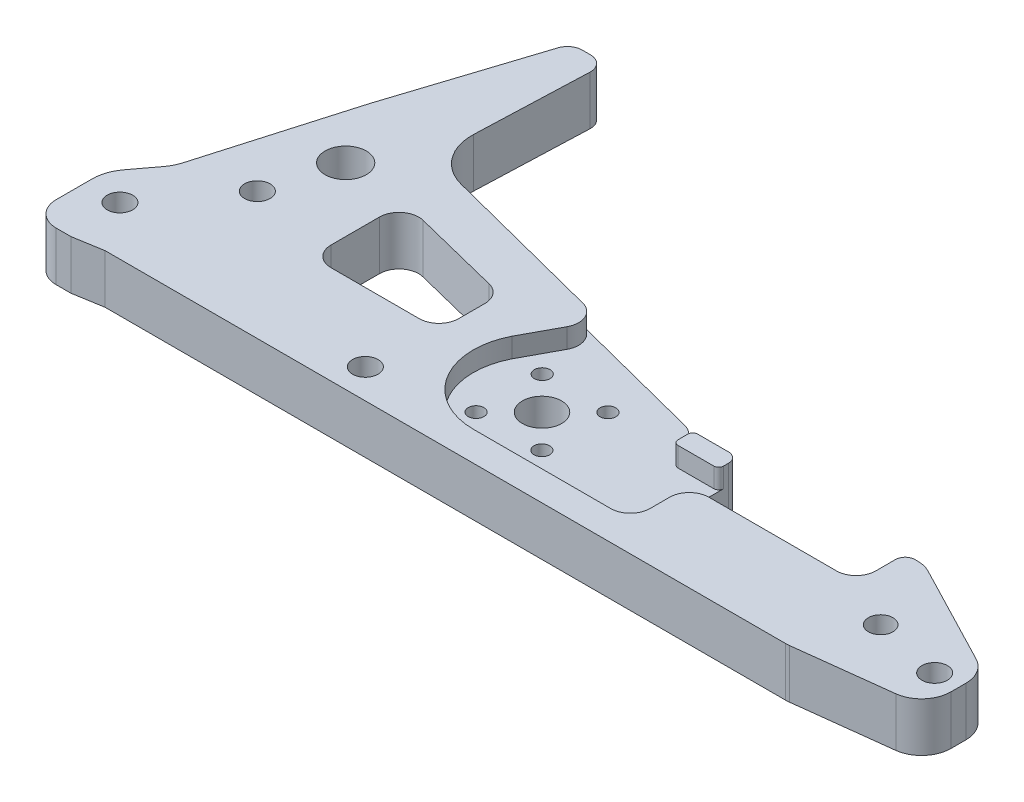
from build123d import *

# Parameters (mm, degrees)
SKETCH1_R           = 2.6
SKETCH1_R_2         = 4.2
SKETCH1_R_3         = 2.5
BOSS_EXTRUDE1_DEPTH = 10
FILLET2_R           = 6
FILLET3_R           = 3
CUT_EXTRUDE1_DEPTH  = 11
SKETCH7_R           = 2.6
CUT_EXTRUDE4_DEPTH  = 11
FILLET8_R           = 5
FILLET9_R           = 4
SKETCH10_W          = 34
SKETCH10_H          = 10
CUT_EXTRUDE6_DEPTH  = 11
FILLET11_R          = 2
CUT_EXTRUDE7_DEPTH  = 4
FILLET13_R          = 10
FILLET14_R          = 4
FILLET15_R          = 1
FILLET16_R          = 4
FILLET17_R          = 4
SKETCH13_R          = 4
CUT_EXTRUDE8_DEPTH  = 10
FILLET19_R          = 8
SKETCH14_R          = 1.6
CUT_EXTRUDE9_DEPTH  = 10


with BuildPart() as part:
    # Sketch1 → Boss-Extrude1 (new body)
    with BuildSketch(Plane(origin=(0, 0, 0), x_dir=(1, 0, 0), z_dir=(0, 1, 0))):
        Polygon((164, 15), (139, 28), (91.716233646, 28), (86.716233646, 32), (16.716233646, 50), (18, 84), (11, 84), (1, 53), (-8, 22), (-14, 14), (-14, 2), (-14, -1), (-6, -1), (0, 0), (139, 0), (164, 3), align=None)
        with Locations((-7, 10)):
            Circle(SKETCH1_R, mode=Mode.SUBTRACT)
        with Locations((159, 10)):
            Circle(SKETCH1_R, mode=Mode.SUBTRACT)
        with Locations((5, 26)):
            Circle(SKETCH1_R, mode=Mode.SUBTRACT)
        with Locations((9, 40)):
            Circle(SKETCH1_R_2, mode=Mode.SUBTRACT)
        with Locations((145, 13)):
            Circle(SKETCH1_R_3, mode=Mode.SUBTRACT)
    extrude(amount=BOSS_EXTRUDE1_DEPTH)

    # Fillet2
    fillet2_edges = [part.edges().sort_by_distance(p)[0] for p in [
        (139, 5, -28),
        (164, 5, -15),
        (164, 5, -3),
        (139, 5, 0),
    ]]
    fillet(fillet2_edges, radius=FILLET2_R)

    # Fillet3
    fillet3_edges = [part.edges().sort_by_distance(p)[0] for p in [
        (11, 5, -84),
        (18, 5, -84),
    ]]
    fillet(fillet3_edges, radius=FILLET3_R)

    # Sketch4 → Cut-Extrude1 (cut, through all)
    with BuildSketch(Plane(origin=(0, 10, 0), x_dir=(1, 0, 0), z_dir=(0, 1, 0))):
        Polygon((22, 39), (22, 20), (48, 20), (48, 32.5), align=None)
    extrude(amount=-CUT_EXTRUDE1_DEPTH, mode=Mode.SUBTRACT)

    # Sketch7 → Cut-Extrude4 (cut, through all)
    with BuildSketch(Plane(origin=(0, 10, 0), x_dir=(1, 0, 0), z_dir=(0, 1, 0))):
        with Locations((47, 6)):
            Circle(SKETCH7_R)
    extrude(amount=-CUT_EXTRUDE4_DEPTH, mode=Mode.SUBTRACT)

    # Fillet8
    fillet8_edges = [part.edges().sort_by_distance(p)[0] for p in [
        (-14, 5, 1),
    ]]
    fillet(fillet8_edges, radius=FILLET8_R)

    # Fillet9
    fillet9_edges = [part.edges().sort_by_distance(p)[0] for p in [
        (22, 5, -39),
        (48, 5, -32.5),
        (48, 5, -20),
        (22, 5, -20),
    ]]
    fillet(fillet9_edges, radius=FILLET9_R)

    # Sketch10 → Cut-Extrude6 (cut, through all)
    with BuildSketch(Plane(origin=(0, 10, 0), x_dir=(1, 0, 0), z_dir=(0, 1, 0))):
        with Locations((118, 23)):
            Rectangle(SKETCH10_W, SKETCH10_H)
    extrude(amount=-CUT_EXTRUDE6_DEPTH, mode=Mode.SUBTRACT)

    # Fillet11
    fillet11_edges = [part.edges().sort_by_distance(p)[0] for p in [
        (101, 5, -28),
        (135, 5, -28),
    ]]
    fillet(fillet11_edges, radius=FILLET11_R)

    # Sketch12 → Cut-Extrude7 (cut)
    with BuildSketch(Plane(origin=(0, 10, 0), x_dir=(1, 0, 0), z_dir=(0, 1, 0))):
        with BuildLine():
            Line((86.716233646, 32), (91.716233646, 28))
            Line((91.716233646, 28), (91.716233646, 24))
            Line((91.716233646, 24), (101, 24))
            Line((101, 24), (101, 6))
            Line((101, 6), (69, 6))
            ThreePointArc((69, 6), (57.064930536, 12.681932162), (56.522621715, 26.349411873))
            Line((56.522621715, 26.349411873), (62.882866971, 38.128580002))
            Line((62.882866971, 38.128580002), (86.716233646, 32))
        make_face()
    extrude(amount=-CUT_EXTRUDE7_DEPTH, mode=Mode.SUBTRACT)

    # Fillet13
    fillet13_edges = [part.edges().sort_by_distance(p)[0] for p in [
        (16.716233646, 5, -50),
    ]]
    fillet(fillet13_edges, radius=FILLET13_R)

    # Fillet14
    fillet14_edges = [part.edges().sort_by_distance(p)[0] for p in [
        (86.716233646, 3, -32),
        (91.716233646, 3, -28),
    ]]
    fillet(fillet14_edges, radius=FILLET14_R)

    # Fillet15
    fillet15_edges = [part.edges().sort_by_distance(p)[0] for p in [
        (91.716233646, 8, -24),
        (101, 8, -24),
        (91.716233646, 8, -28),
    ]]
    fillet(fillet15_edges, radius=FILLET15_R)

    # Fillet16
    fillet16_edges = [part.edges().sort_by_distance(p)[0] for p in [
        (101, 8, -18),
        (62.882866971, 8, -38.128580002),
    ]]
    fillet(fillet16_edges, radius=FILLET16_R)

    # Fillet17
    fillet17_edges = [part.edges().sort_by_distance(p)[0] for p in [
        (101, 3, -18),
        (101, 8, -6),
        (135, 5, -18),
    ]]
    fillet(fillet17_edges, radius=FILLET17_R)

    # Sketch13 → Cut-Extrude8 (cut)
    with BuildSketch(Plane(origin=(0, 6, 0), x_dir=(1, 0, 0), z_dir=(0, 1, 0))):
        with Locations((69, 20)):
            Circle(SKETCH13_R)
    extrude(amount=-CUT_EXTRUDE8_DEPTH, mode=Mode.SUBTRACT)

    # Fillet19
    fillet19_edges = [part.edges().sort_by_distance(p)[0] for p in [
        (-14, 5, -14),
        (-8, 5, -22),
    ]]
    fillet(fillet19_edges, radius=FILLET19_R)

    # Sketch14 → Cut-Extrude9 (cut)
    with BuildSketch(Plane(origin=(0, 6, 0), x_dir=(1, 0, 0), z_dir=(0, 1, 0))):
        with Locations((62.3, 26.734983296)):
            Circle(SKETCH14_R)
        with Locations((75.734983296, 26.7)):
            Circle(SKETCH14_R)
        with Locations((75.7, 13.265016704)):
            Circle(SKETCH14_R)
        with Locations((62.265016704, 13.3)):
            Circle(SKETCH14_R)
    extrude(amount=-CUT_EXTRUDE9_DEPTH, mode=Mode.SUBTRACT)


solid = part.part
